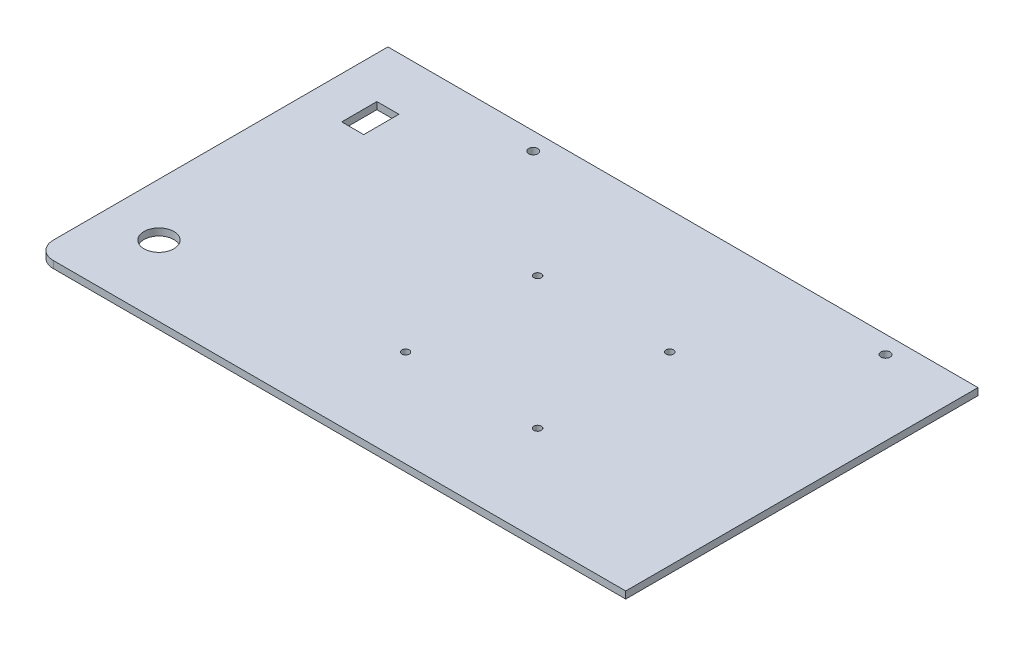
from build123d import *

# Parameters (mm, degrees)
SKETCH_1_W             = 285
SKETCH_1_H             = 200
EXTRUDE_1_DEPTH        = 4
SKETCH_2_R             = 2.1
SKETCH_2_R_2           = 2.6
CUT_EXTRUDE_1_DEPTH    = 5
SKETCH_3_W             = 200
SKETCH_3_H             = 4
EXTRUDE_1002_DEPTH     = 50
SKETCH_4_R             = 8.5
SKETCH_4_W             = 12.5
SKETCH_4_H             = 20
CUT_EXTRUDE_1350_DEPTH = 5
FILLET_1_R             = 10


with BuildPart() as part:
    # 草图1 → 凸台-拉伸1 (new body)
    with BuildSketch(Plane(origin=(0, 0, 0), x_dir=(1, 0, 0), z_dir=(0, 1, 0))):
        Rectangle(SKETCH_1_W, SKETCH_1_H)
    extrude(amount=EXTRUDE_1_DEPTH)

    # 草图2 → 切除-拉伸1 (cut, through all)
    with BuildSketch(Plane(origin=(0, 4, 0), x_dir=(1, 0, 0), z_dir=(0, 1, 0))):
        with Locations((-37.5, 30)):
            Circle(SKETCH_2_R)
        with Locations((37.5, 30)):
            Circle(SKETCH_2_R)
        with Locations((37.5, -45)):
            Circle(SKETCH_2_R)
        with Locations((-37.5, -45)):
            Circle(SKETCH_2_R)
        with Locations((-100, 90)):
            Circle(SKETCH_2_R_2)
        with Locations((100, 90)):
            Circle(SKETCH_2_R_2)
    extrude(amount=-CUT_EXTRUDE_1_DEPTH, mode=Mode.SUBTRACT)

    # 草图3 → Extrude 1002 (add)
    with BuildSketch(Plane.ZY.offset(142.5)):
        with Locations((0, 2)):
            Rectangle(SKETCH_3_W, SKETCH_3_H)
    extrude(amount=EXTRUDE_1002_DEPTH)

    # 草图4 → Cut-Extrude 1350 (cut, through all)
    with BuildSketch(Plane.XZ):
        with Locations((-162.5, 60)):
            Circle(SKETCH_4_R)
        with Locations((-162.5, -60)):
            Rectangle(SKETCH_4_W, SKETCH_4_H)
    extrude(amount=-CUT_EXTRUDE_1350_DEPTH, mode=Mode.SUBTRACT)

    # 圆角1
    fillet_1_edges = [part.edges().sort_by_distance(p)[0] for p in [
        (-192.5, 2, 100),
    ]]
    fillet(fillet_1_edges, radius=FILLET_1_R)


solid = part.part
